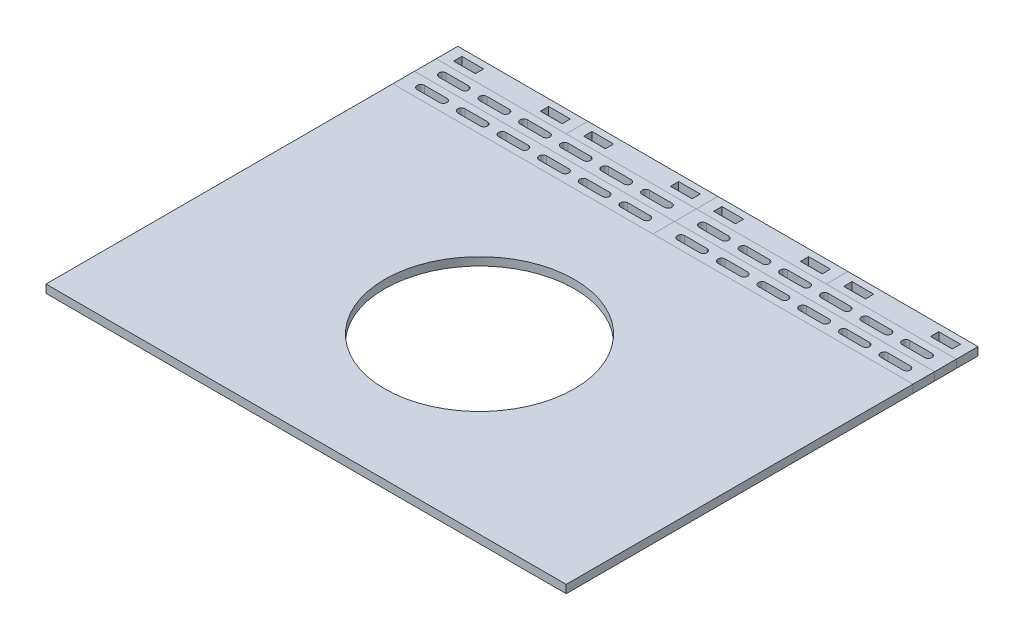
from build123d import *

# Parameters (mm, degrees)
SKETCH1_W           = 304.8
SKETCH1_H           = 203.2
SKETCH1_R           = 55.5625
BOSS_EXTRUDE1_DEPTH = 4.7625
SKETCH3_W           = 152.4
SKETCH3_H           = 12.7
BOSS_EXTRUDE2_DEPTH = 4.7625
CUT_EXTRUDE1_DEPTH  = 4.7625
LPATTERN2_COUNT     = 6
LPATTERN2_PITCH     = 23.8125
LPATTERN3_COUNT     = 2
LPATTERN3_PITCH     = 12.7
LPATTERN3_2_COUNT   = 2
LPATTERN3_2_PITCH   = 152.4
SKETCH5_W           = 76.2
SKETCH5_H           = 12.7
BOSS_EXTRUDE3_DEPTH = 4.7625
SKETCH6_W           = 12.7508
SKETCH6_H           = 4.826
SKETCH6_W_2         = 12.7
CUT_EXTRUDE2_DEPTH  = 4.7625
LPATTERN4_COUNT     = 4
LPATTERN4_PITCH     = 76.2


with BuildPart() as part:
    # Sketch1 → Boss-Extrude1 (new body)
    with BuildSketch(Plane(origin=(0, 0, 0), x_dir=(1, 0, 0), z_dir=(0, 1, 0))):
        with Locations((152.4, 101.6)):
            Rectangle(SKETCH1_W, SKETCH1_H)
        with Locations((152.4, 101.6)):
            Circle(SKETCH1_R, mode=Mode.SUBTRACT)
    extrude(amount=BOSS_EXTRUDE1_DEPTH)


with BuildPart() as body_2:
    # Sketch3 → Boss-Extrude2 (new body)
    with BuildSketch(Plane(origin=(0, 0, 0), x_dir=(1, 0, 0), z_dir=(0, 1, 0))):
        with Locations((76.2, 209.55)):
            Rectangle(SKETCH3_W, SKETCH3_H)
    extrude(amount=BOSS_EXTRUDE2_DEPTH)

    # Sketch4 → Cut-Extrude1 (cut)
    with BuildSketch(Plane(origin=(0, 4.7625, 0), x_dir=(1, 0, 0), z_dir=(0, 1, 0))):
        with BuildLine():
            Line((10.0838, 211.6963), (23.2537, 211.6963))
            ThreePointArc((23.2537, 211.6963), (25.4, 209.55), (23.2537, 207.4037))
            Line((23.2537, 207.4037), (10.0838, 207.4037))
            ThreePointArc((10.0838, 207.4037), (7.9375, 209.55), (10.0838, 211.6963))
        make_face()
    cut_extrude1 = extrude(amount=-CUT_EXTRUDE1_DEPTH, mode=Mode.SUBTRACT)

    # LPattern2: Cut-Extrude1 ×6
    with Locations(*[(i * LPATTERN2_PITCH, 0, 0) for i in range(1, LPATTERN2_COUNT)]):
        add(cut_extrude1, mode=Mode.SUBTRACT)


with BuildPart() as lpattern3_1:
    # LPattern3: pattern copy
    add(body_2.part.moved(Location(Vector(0, 0, -1) * (1 * LPATTERN3_PITCH))))


with BuildPart() as lpattern3_2_1:
    # LPattern3 2: pattern copy
    add(body_2.part.moved(Location(Vector(1, 0, 0) * (1 * LPATTERN3_2_PITCH))))


with BuildPart() as lpattern3_2_2:
    # LPattern3 2: pattern copy
    add(lpattern3_1.part.moved(Location(Vector(1, 0, 0) * (1 * LPATTERN3_2_PITCH))))


with BuildPart() as body_6:
    # Sketch5 → Boss-Extrude3 (new body)
    with BuildSketch(Plane(origin=(0, 0, 0), x_dir=(1, 0, 0), z_dir=(0, 1, 0))):
        with Locations((38.1, 234.95)):
            Rectangle(SKETCH5_W, SKETCH5_H)
    extrude(amount=BOSS_EXTRUDE3_DEPTH)

    # Sketch6 → Cut-Extrude2 (cut)
    with BuildSketch(Plane(origin=(0, 4.7625, 0), x_dir=(1, 0, 0), z_dir=(0, 1, 0))):
        with Locations((12.6746, 234.95)):
            Rectangle(SKETCH6_W, SKETCH6_H)
        with Locations((63.5, 234.95)):
            Rectangle(SKETCH6_W_2, SKETCH6_H)
    extrude(amount=-CUT_EXTRUDE2_DEPTH, mode=Mode.SUBTRACT)


with BuildPart() as lpattern4_1:
    # LPattern4: pattern copy
    add(body_6.part.moved(Location(Vector(1, 0, 0) * (1 * LPATTERN4_PITCH))))


with BuildPart() as lpattern4_2:
    # LPattern4: pattern copy
    add(body_6.part.moved(Location(Vector(1, 0, 0) * (2 * LPATTERN4_PITCH))))


with BuildPart() as lpattern4_3:
    # LPattern4: pattern copy
    add(body_6.part.moved(Location(Vector(1, 0, 0) * (3 * LPATTERN4_PITCH))))


solid = Compound([part.part, body_2.part, lpattern3_1.part, lpattern3_2_1.part, lpattern3_2_2.part, body_6.part, lpattern4_1.part, lpattern4_2.part, lpattern4_3.part])
